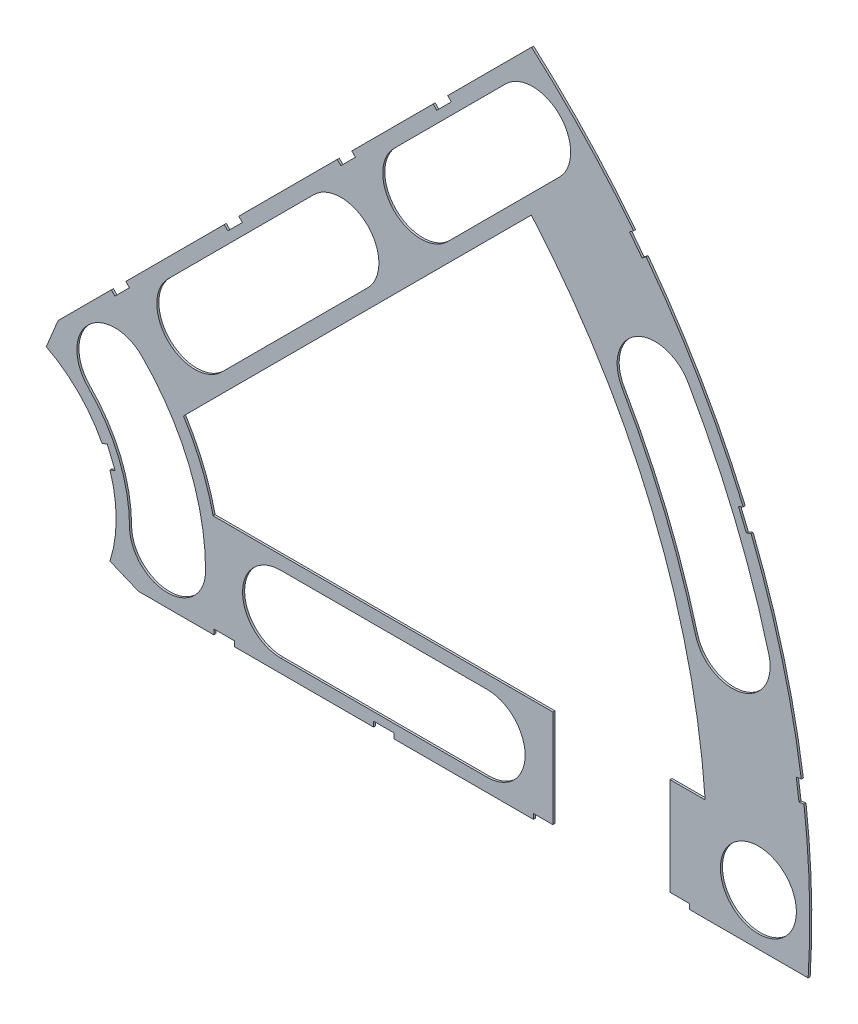
from build123d import *

# Parameters (mm, degrees)
BOSS_EXTRUDE1_DEPTH = 0.254
SKETCH2_R           = 4.699
CUT_EXTRUDE1_DEPTH  = 1.254
SKETCH3_W           = 2.54
SKETCH3_H           = 0.635
CUT_EXTRUDE2_DEPTH  = 1.254
CUT_EXTRUDE4_DEPTH  = 1.254
SKETCH5_W           = 14.478
SKETCH5_H           = 15.24
CUT_EXTRUDE5_DEPTH  = 1.254


with BuildPart() as part:
    # Sketch1 → Boss-Extrude1 (new body)
    with BuildSketch(Plane.XY):
        with BuildLine():
            Line((67.21146711, 76.191723231), (8.696654013, 17.676910134))
            Line((8.696654013, 17.676910134), (7.228954972, 14.133571205))
            ThreePointArc((7.228954972, 14.133571205), (14.666587579, 6.075099489), (15.105587123, -4.88230096))
            Line((15.105587123, -4.88230096), (18.648926052, -6.35))
            Line((18.648926052, -6.35), (101.401368334, -6.35))
            ThreePointArc((101.401368334, -6.35), (93.866160503, 38.880636728), (67.21146711, 76.191723231))
        make_face()
        with BuildLine():
            Line((88.672924278, 6.35), (27.86051193, 6.35))
            ThreePointArc((27.86051193, 6.35), (26.399857642, 10.93517908), (24.190484974, 15.210228852))
            Line((24.190484974, 15.210228852), (67.191354125, 58.211098004))
            ThreePointArc((67.191354125, 58.211098004), (82.13289044, 34.020557137), (88.672924278, 6.35))
        make_face(mode=Mode.SUBTRACT)
    extrude(amount=BOSS_EXTRUDE1_DEPTH)

    # Sketch2 → Cut-Extrude1 (cut, through all)
    with BuildSketch(Plane.XY.offset(0.254)):
        with Locations((22.225, 0)):
            Circle(SKETCH2_R)
        with Locations((36.195, 0)):
            Circle(SKETCH2_R)
        with Locations((61.722, 0)):
            Circle(SKETCH2_R)
        with Locations((75.692, 0)):
            Circle(SKETCH2_R)
        with Locations((95.25, 0)):
            Circle(SKETCH2_R)
        with Locations((15.715448212, 15.715448212)):
            Circle(SKETCH2_R)
        with Locations((25.593729945, 25.593729945)):
            Circle(SKETCH2_R)
        with Locations((43.644044748, 43.644044748)):
            Circle(SKETCH2_R)
        with Locations((53.522326482, 53.522326482)):
            Circle(SKETCH2_R)
        with Locations((92.004434954, 24.652514046)):
            Circle(SKETCH2_R)
        with Locations((82.48891971, 47.625)):
            Circle(SKETCH2_R)
        with Locations((67.351920908, 67.351920908)):
            Circle(SKETCH2_R)
    extrude(amount=-CUT_EXTRUDE1_DEPTH, mode=Mode.SUBTRACT)

    # Sketch3 → Cut-Extrude2 (cut, through all)
    with BuildSketch(Plane.XY.offset(0.254)):
        Polygon((15.266435406, 24.246691527), (17.06248663, 26.042742751), (17.511499436, 25.593729945), (15.715448212, 23.797678721), align=None)
        Polygon((44.991083167, 53.971339288), (43.195031942, 52.175288063), (43.644044748, 51.726275257), (45.440095973, 53.522326482), align=None)
        with Locations((29.21, -6.0325)):
            Rectangle(SKETCH3_W, SKETCH3_H)
        with Locations((68.707, -6.0325)):
            Rectangle(SKETCH3_W, SKETCH3_H)
        Polygon((29.230733674, 38.210989795), (31.026784898, 40.007041019), (31.475797704, 39.558028213), (29.67974648, 37.761976989), align=None)
        Polygon((56.845021246, 65.825277367), (55.048970022, 64.029226143), (55.497982828, 63.580213337), (57.294034052, 65.376264561), align=None)
        with Locations((48.9585, -6.0325)):
            Rectangle(SKETCH3_W, SKETCH3_H)
        with Locations((85.471, -6.0325)):
            Rectangle(SKETCH3_W, SKETCH3_H)
        Polygon((99.935462164, 14.437711971), (100.266998693, 11.919442024), (101.526133667, 12.085210288), (101.194597138, 14.603480236), align=None)
        Polygon((93.765504959, 37.464305742), (94.938831965, 37.950313702), (93.966816047, 40.296967714), (92.793489041, 39.810959755), align=None)
        Polygon((79.327792988, 62.471156422), (80.874047017, 60.456038938), (81.88160576, 61.229165953), (80.33535173, 63.244283437), align=None)
        Polygon((13.593916116, 7.005422516), (14.565932035, 4.658768503), (15.739259041, 5.144776462), (14.767243123, 7.491430475), align=None)
    extrude(amount=-CUT_EXTRUDE2_DEPTH, mode=Mode.SUBTRACT)

    # Sketch6 → Cut-Extrude4 (cut, through all)
    with BuildSketch(Plane.XY.offset(0.254)):
        with BuildLine():
            Line((22.27103518, 28.91642471), (40.321349984, 46.966739513))
            ThreePointArc((40.321349984, 46.966739513), (46.966739513, 46.966739513), (46.966739513, 40.321349984))
            Line((46.966739513, 40.321349984), (28.91642471, 22.27103518))
            ThreePointArc((28.91642471, 22.27103518), (22.27103518, 22.27103518), (22.27103518, 28.91642471))
        make_face()
        with BuildLine():
            Line((50.199631717, 56.845021246), (64.029226143, 70.674615673))
            ThreePointArc((64.029226143, 70.674615673), (70.674615673, 70.674615673), (70.674615673, 64.029226143))
            Line((70.674615673, 64.029226143), (56.845021246, 50.199631717))
            ThreePointArc((56.845021246, 50.199631717), (50.199631717, 50.199631717), (50.199631717, 56.845021246))
        make_face()
        with BuildLine():
            Line((61.722, -4.699), (36.195, -4.699))
            ThreePointArc((36.195, -4.699), (31.496, 0), (36.195, 4.699))
            Line((36.195, 4.699), (61.722, 4.699))
            ThreePointArc((61.722, 4.699), (66.421, 0), (61.722, -4.699))
        make_face()
        with BuildLine():
            ThreePointArc((26.924, 0), (24.874532533, 10.303368733), (19.038142977, 19.038142977))
            ThreePointArc((19.038142977, 19.038142977), (12.392753447, 19.038142977), (12.392753447, 12.392753447))
            ThreePointArc((12.392753447, 12.392753447), (16.191912687, 6.706909836), (17.526, 0))
            ThreePointArc((17.526, 0), (22.225, -4.699), (26.924, 0))
        make_face()
        with BuildLine():
            ThreePointArc((96.543320412, 25.868704739), (92.340835395, 38.248826381), (86.558373083, 49.9745))
            ThreePointArc((86.558373083, 49.9745), (80.13941971, 51.694453372), (78.419466338, 45.2755))
            ThreePointArc((78.419466338, 45.2755), (83.658215548, 34.652367484), (87.465549496, 23.436323353))
            ThreePointArc((87.465549496, 23.436323353), (93.220625647, 20.113628588), (96.543320412, 25.868704739))
        make_face()
    extrude(amount=-CUT_EXTRUDE4_DEPTH, mode=Mode.SUBTRACT)

    # Sketch5 → Cut-Extrude5 (cut, through all)
    with BuildSketch(Plane.XY.offset(0.254)):
        with Locations((77.089, 0)):
            Rectangle(SKETCH5_W, SKETCH5_H)
    extrude(amount=-CUT_EXTRUDE5_DEPTH, mode=Mode.SUBTRACT)


solid = part.part
